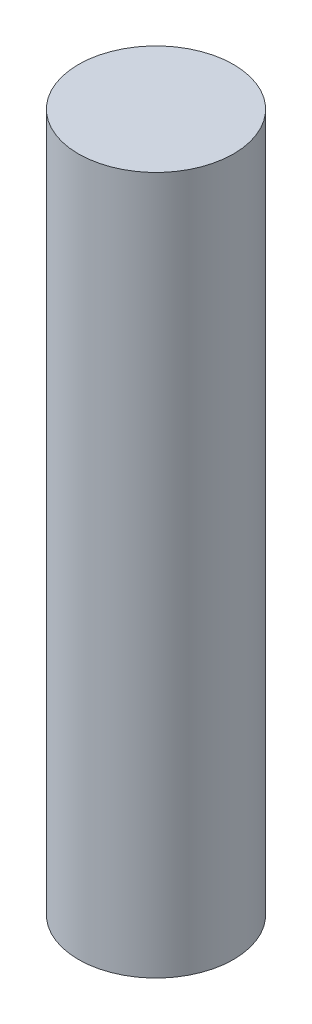
from build123d import *

# Parameters (mm, degrees)
SKETCH1_R           = 3.175
BOSS_EXTRUDE1_DEPTH = 28.575


with BuildPart() as part:
    # Sketch1 → Boss-Extrude1 (new body)
    with BuildSketch(Plane(origin=(0, 0, 0), x_dir=(1, 0, 0), z_dir=(0, 1, 0))):
        Circle(SKETCH1_R)
    extrude(amount=BOSS_EXTRUDE1_DEPTH)


solid = part.part
